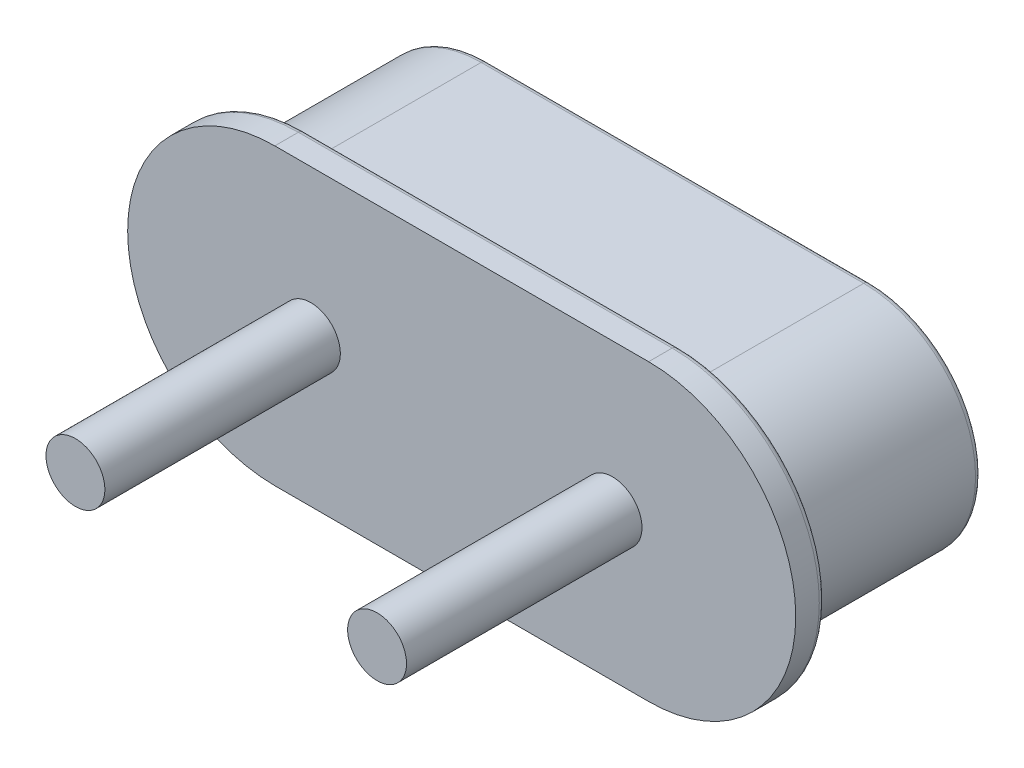
from build123d import *

# Parameters (mm, degrees)
BOSS_EXTRUDE1_DEPTH = 0.5
BOSS_EXTRUDE2_DEPTH = 3.18
FILLET5_R           = 0.1
FILLET6_R           = 0.1
SKETCH7_R           = 0.5
BOSS_EXTRUDE3_DEPTH = 4
BOSS_EXTRUDE4_DEPTH = 0.01


with BuildPart() as part:
    # Sketch1 → Boss-Extrude1 (new body)
    with BuildSketch(Plane.XY):
        with BuildLine():
            Line((-3.175, 2.5), (3.175, 2.5))
            ThreePointArc((3.175, 2.5), (5.675, 0), (3.175, -2.5))
            Line((3.175, -2.5), (-3.175, -2.5))
            ThreePointArc((-3.175, -2.5), (-5.675, 0), (-3.175, 2.5))
        make_face()
    extrude(amount=-BOSS_EXTRUDE1_DEPTH)

    # Sketch3 → Boss-Extrude2 (add)
    with BuildSketch(Plane(origin=(0, 0, -0.5), x_dir=(-1, 0, 0), z_dir=(0, 0, -1))):
        with BuildLine():
            Line((-3.25, 1.9), (3.25, 1.9))
            ThreePointArc((3.25, 1.9), (5.15, 0), (3.25, -1.9))
            Line((3.25, -1.9), (-3.25, -1.9))
            ThreePointArc((-3.25, -1.9), (-5.15, 0), (-3.25, 1.9))
        make_face()
    extrude(amount=BOSS_EXTRUDE2_DEPTH)

    # Fillet5
    fillet5_edges = [part.edges().sort_by_distance(p)[0] for p in [
        (5.15, 0, -3.68),
        (0, -1.9, -3.68),
        (-5.15, 0, -3.68),
        (0, 1.9, -3.68),
    ]]
    fillet(fillet5_edges, radius=FILLET5_R)

    # Fillet6
    fillet6_edges = [part.edges().sort_by_distance(p)[0] for p in [
        (5.675, 0, -0.5),
        (0, 2.5, -0.5),
        (-5.675, 0, -0.5),
        (0, -2.5, -0.5),
    ]]
    fillet(fillet6_edges, radius=FILLET6_R)

    # Sketch7 → Boss-Extrude3 (add)
    with BuildSketch(Plane.XY):
        with Locations((2.5623, 0)):
            Circle(SKETCH7_R)
        with Locations((-2.5623, 0)):
            Circle(SKETCH7_R)
    extrude(amount=BOSS_EXTRUDE3_DEPTH)

    # Sketch8 → Boss-Extrude4 (add)
    with BuildSketch(Plane(origin=(0, 0, -3.68), x_dir=(-1, 0, 0), z_dir=(0, 0, -1))):
        Polygon((-2.690553742, 0.764659829), (-2.413209992, 0.764659829), (-2.413209992, -0.735340171), (-2.547825377, -0.735340171), (-2.547825377, 0.610813675), (-2.778594608, 0.610813675), align=None)
        with BuildLine():
            Line((-1.163209992, 0.803121367), (-1.059544127, 0.721691079))
            Line((-1.059544127, 0.721691079), (-1.455878261, 0.115621367))
            add(Edge.make_bspline(
                [(-1.455878261, 0.115621367), (-1.429491, 0.119827307), (-1.378019663, 0.12803147), (-1.325919992, 0.129384875), (-1.300529704, 0.130044444)],
                knots=[0, 0, 0, 0, 8.0061e-05, 0.000156168, 0.000156168, 0.000156168, 0.000156168], degree=3))
            add(Edge.make_bspline(
                [(-1.300529704, 0.130044444), (-1.285284348, 0.129634682), (-1.255274319, 0.128828077), (-1.211214261, 0.122620713), (-1.168876146, 0.112838522), (-1.128435455, 0.098578984), (-1.089747034, 0.080363689), (-1.052588864, 0.058532745), (-1.017659432, 0.031958882), (-0.984508926, 0.0022739), (-0.954411599, -0.030604807), (-0.927764718, -0.065491094), (-0.905381807, -0.102348615), (-0.887221555, -0.1411587), (-0.873119464, -0.181861526), (-0.862839045, -0.224405014), (-0.856762076, -0.268818502), (-0.855936866, -0.299023434), (-0.855517685, -0.314366614)],
                knots=[0, 0, 0, 0, 4.5721e-05, 9.0001e-05, 0.000133222, 0.000175891, 0.000218368, 0.000261346, 0.000304916, 0.000349809, 0.000394681, 0.000438432, 0.000481307, 0.000523784, 0.000566737, 0.000610319, 0.000654897, 0.000700919, 0.000700919, 0.000700919, 0.000700919], degree=3))
            add(Edge.make_bspline(
                [(-0.855517685, -0.314366614), (-0.856127587, -0.335357915), (-0.85732773, -0.376663829), (-0.869286499, -0.436825275), (-0.887869204, -0.49413921), (-0.914431002, -0.547690569), (-0.947423452, -0.597405956), (-0.987656706, -0.64145687), (-1.033703915, -0.680744029), (-1.085769686, -0.713596866), (-1.141802385, -0.740426745), (-1.200667527, -0.759697563), (-1.261793446, -0.771561907), (-1.303281136, -0.773049308), (-1.324267685, -0.77380171)],
                knots=[0, 0, 0, 0, 6.2904e-05, 0.00012378, 0.000183263, 0.000243197, 0.000302535, 0.000361677, 0.000421581, 0.000483597, 0.000545827, 0.000607495, 0.000668962, 0.000731884, 0.000731884, 0.000731884, 0.000731884], degree=3))
            add(Edge.make_bspline(
                [(-1.324267685, -0.77380171), (-1.344451985, -0.773146764), (-1.38443355, -0.771849432), (-1.443247604, -0.760292602), (-1.499760326, -0.741560986), (-1.553575775, -0.715754867), (-1.603427466, -0.683158631), (-1.648027025, -0.643917655), (-1.687152071, -0.598870741), (-1.719712623, -0.548024878), (-1.745537794, -0.493386325), (-1.764904904, -0.436413258), (-1.77621758, -0.377313266), (-1.77779839, -0.33724992), (-1.778594608, -0.31707094)],
                knots=[0, 0, 0, 0, 6.0504e-05, 0.000119848, 0.000179046, 0.000238718, 0.000298389, 0.000357156, 0.000416376, 0.000476803, 0.000537689, 0.000597267, 0.000656906, 0.000717429, 0.000717429, 0.000717429, 0.000717429], degree=3))
            add(Edge.make_bspline(
                [(-1.778594608, -0.31707094), (-1.778088274, -0.301623262), (-1.777054438, -0.270082054), (-1.769835842, -0.222311756), (-1.758236644, -0.173432721), (-1.745246538, -0.131966638), (-1.731521277, -0.097997415), (-1.72009876, -0.070610204), (-1.705881333, -0.042426887), (-1.690721313, -0.012481043), (-1.673254083, 0.018455571), (-1.654261662, 0.050900001), (-1.633218954, 0.084336255), (-1.618467456, 0.107026625), (-1.610926338, 0.118626175)],
                knots=[0, 0, 0, 0, 4.6336e-05, 9.461e-05, 0.000144609, 0.00019697, 0.000224757, 0.000254506, 0.000285952, 0.000319415, 0.000355196, 0.000392507, 0.000432193, 0.0004737, 0.0004737, 0.0004737, 0.0004737], degree=3))
            Line((-1.610926338, 0.118626175), (-1.163209992, 0.803121367))
        make_face()
        with BuildLine():
            add(Edge.make_bspline(
                [(-1.328774896, -0.02380171), (-1.340201572, -0.024135157), (-1.362521191, -0.024786476), (-1.395267226, -0.028568727), (-1.426258619, -0.035691184), (-1.455905962, -0.044762469), (-1.483654978, -0.057235209), (-1.509707338, -0.07238598), (-1.534163788, -0.090223628), (-1.556768168, -0.110495447), (-1.577262309, -0.132690318), (-1.594911365, -0.15646297), (-1.610135251, -0.181240486), (-1.622513173, -0.20722989), (-1.632151777, -0.234421247), (-1.639123885, -0.262689497), (-1.643004064, -0.292224199), (-1.643649592, -0.312252415), (-1.643979223, -0.322479594)],
                knots=[0, 0, 0, 0, 3.4288e-05, 6.6974e-05, 9.8686e-05, 0.000129571, 0.000159836, 0.000189728, 0.000219839, 0.000250482, 0.00028068, 0.000310307, 0.000339166, 0.000367794, 0.000396495, 0.000425574, 0.000454981, 0.000485667, 0.000485667, 0.000485667, 0.000485667], degree=3))
            add(Edge.make_bspline(
                [(-1.643979223, -0.322479594), (-1.643710782, -0.3326153), (-1.64318441, -0.35248991), (-1.638404845, -0.38177813), (-1.631104095, -0.40996309), (-1.620243925, -0.43689949), (-1.607289545, -0.462997912), (-1.590187263, -0.487313034), (-1.571237212, -0.511321636), (-1.548585526, -0.533179409), (-1.524275513, -0.553517962), (-1.498303569, -0.571295214), (-1.471235015, -0.586503574), (-1.442704406, -0.598422616), (-1.413116527, -0.608204453), (-1.382224861, -0.615087944), (-1.350007923, -0.618979598), (-1.328184235, -0.619625967), (-1.317056146, -0.619955556)],
                knots=[0, 0, 0, 0, 3.0386e-05, 5.9582e-05, 8.8809e-05, 0.000117545, 0.000146572, 0.000175992, 0.000206542, 0.000238201, 0.000270211, 0.000301549, 0.000332485, 0.000363181, 0.000394158, 0.00042587, 0.00045796, 0.000491347, 0.000491347, 0.000491347, 0.000491347], degree=3))
            add(Edge.make_bspline(
                [(-1.317056146, -0.619955556), (-1.305928075, -0.619625941), (-1.284104423, -0.618979522), (-1.251887226, -0.615088235), (-1.220996518, -0.608203386), (-1.191405157, -0.598426484), (-1.162887401, -0.586489223), (-1.13584252, -0.571389829), (-1.110116195, -0.553408636), (-1.085790223, -0.533214166), (-1.063232821, -0.51119723), (-1.043828273, -0.487527349), (-1.027249745, -0.462801394), (-1.01377795, -0.437002298), (-1.003037397, -0.409946803), (-0.995699625, -0.381782493), (-0.99092993, -0.352488768), (-0.990402201, -0.332614914), (-0.990133069, -0.322479594)],
                knots=[0, 0, 0, 0, 3.3387e-05, 6.5477e-05, 9.7189e-05, 0.000128166, 0.000158862, 0.000189798, 0.000220889, 0.000252898, 0.000284557, 0.000315298, 0.000344549, 0.000373715, 0.000402451, 0.000431678, 0.000460874, 0.00049126, 0.00049126, 0.00049126, 0.00049126], degree=3))
            add(Edge.make_bspline(
                [(-0.990133069, -0.322479594), (-0.990368909, -0.312239073), (-0.990831786, -0.292140259), (-0.996067192, -0.262702708), (-1.00332821, -0.23427762), (-1.014292366, -0.207043641), (-1.028536599, -0.181108244), (-1.045886631, -0.156340415), (-1.065957732, -0.132550266), (-1.089142392, -0.11045192), (-1.114381064, -0.090246029), (-1.141216315, -0.072409076), (-1.169291161, -0.057355515), (-1.198577136, -0.044795328), (-1.2294098, -0.035731268), (-1.261291374, -0.028594164), (-1.294629621, -0.024796156), (-1.317248167, -0.024137414), (-1.328774896, -0.02380171)],
                knots=[0, 0, 0, 0, 3.0686e-05, 6.0226e-05, 8.9453e-05, 0.00011858, 0.000148029, 0.000178036, 0.000209162, 0.000241251, 0.000273959, 0.000306045, 0.000337772, 0.000369416, 0.000401449, 0.000434041, 0.000467324, 0.000501912, 0.000501912, 0.000501912, 0.000501912], degree=3))
        make_face(mode=Mode.SUBTRACT)
        with BuildLine():
            add(Edge.make_bspline(
                [(-0.461286915, -0.50457094), (-0.452933967, -0.505067298), (-0.436558989, -0.506040348), (-0.412885077, -0.512716065), (-0.391458794, -0.524569777), (-0.372373546, -0.54036811), (-0.356642199, -0.559523395), (-0.344366048, -0.580778784), (-0.337748483, -0.604650895), (-0.336782521, -0.621120756), (-0.336286915, -0.62957094)],
                knots=[0, 0, 0, 0, 2.5055e-05, 4.9118e-05, 7.3051e-05, 9.802e-05, 0.000122989, 0.000147067, 0.00017113, 0.000196484, 0.000196484, 0.000196484, 0.000196484], degree=3))
            add(Edge.make_bspline(
                [(-0.336286915, -0.62957094), (-0.336799316, -0.637818082), (-0.337809762, -0.654081323), (-0.344350879, -0.677773379), (-0.356735758, -0.699042052), (-0.372265041, -0.718457254), (-0.391463512, -0.734289056), (-0.412935732, -0.746041918), (-0.436503414, -0.753195624), (-0.452924696, -0.754106894), (-0.461286915, -0.75457094)],
                knots=[0, 0, 0, 0, 2.4756e-05, 4.8819e-05, 7.2897e-05, 9.8098e-05, 0.000123067, 0.000147, 0.000171147, 0.000196203, 0.000196203, 0.000196203, 0.000196203], degree=3))
            add(Edge.make_bspline(
                [(-0.461286915, -0.75457094), (-0.469655161, -0.754123685), (-0.485992167, -0.753250524), (-0.509471879, -0.745895035), (-0.531074866, -0.734399267), (-0.550269599, -0.718427734), (-0.565928944, -0.699141958), (-0.577768394, -0.677626903), (-0.584878458, -0.654149144), (-0.585813546, -0.63783144), (-0.586286915, -0.62957094)],
                knots=[0, 0, 0, 0, 2.5055e-05, 4.8915e-05, 7.3112e-05, 9.8081e-05, 0.000123282, 0.000147215, 0.000171362, 0.000196119, 0.000196119, 0.000196119, 0.000196119], degree=3))
            add(Edge.make_bspline(
                [(-0.586286915, -0.62957094), (-0.58583173, -0.621106921), (-0.584943036, -0.604581961), (-0.577753468, -0.5809252), (-0.566020805, -0.559424441), (-0.55016135, -0.540397335), (-0.531079509, -0.524459919), (-0.509523993, -0.512860722), (-0.485935618, -0.50598626), (-0.469645645, -0.505050896), (-0.461286915, -0.50457094)],
                knots=[0, 0, 0, 0, 2.5355e-05, 4.9502e-05, 7.3435e-05, 9.8404e-05, 0.000123372, 0.00014757, 0.000171344, 0.0001964, 0.0001964, 0.0001964, 0.0001964], degree=3))
        make_face()
        with BuildLine():
            add(Edge.make_bspline(
                [(-0.143979223, 0.014058867), (-0.143838644, 0.038100605), (-0.143565567, 0.084802027), (-0.140527672, 0.152852588), (-0.135481097, 0.216692711), (-0.12856508, 0.276325454), (-0.120148803, 0.33176621), (-0.108913594, 0.38286682), (-0.096136679, 0.429863795), (-0.081328488, 0.472910387), (-0.064619435, 0.512586545), (-0.046433323, 0.549625917), (-0.026048411, 0.58397246), (-0.004629734, 0.61617437), (0.018689725, 0.645704525), (0.043246349, 0.672979952), (0.069998582, 0.697370273), (0.098037014, 0.719590117), (0.127615499, 0.739068462), (0.157890927, 0.75622535), (0.189071687, 0.770882436), (0.221242908, 0.782406909), (0.254115433, 0.791925843), (0.287804176, 0.798435392), (0.32236476, 0.80253121), (0.345692518, 0.802922782), (0.357523181, 0.803121367)],
                knots=[0, 0, 0, 0, 7.2121e-05, 0.000140096, 0.000204302, 0.000264197, 0.000320168, 0.000372446, 0.000421069, 0.000466206, 0.000508898, 0.000550152, 0.000589885, 0.000628638, 0.000666087, 0.000702672, 0.00073861, 0.000774558, 0.000809893, 0.000844741, 0.000878887, 0.000913107, 0.000947158, 0.000981455, 0.001015932, 0.001051409, 0.001051409, 0.001051409, 0.001051409], degree=3))
            add(Edge.make_bspline(
                [(0.357523181, 0.803121367), (0.369452672, 0.802912304), (0.393176675, 0.802496542), (0.428251122, 0.798500566), (0.462515271, 0.791870085), (0.495823045, 0.782475382), (0.528448039, 0.770820092), (0.560135071, 0.756211327), (0.591080963, 0.739206098), (0.620793944, 0.719224437), (0.649600207, 0.696946318), (0.676792191, 0.671762317), (0.702372371, 0.643926723), (0.726661788, 0.613737353), (0.748971329, 0.580615174), (0.770217086, 0.54513627), (0.789233673, 0.506680185), (0.807548534, 0.465888556), (0.823357242, 0.421632702), (0.837614204, 0.37416209), (0.849133762, 0.32291601), (0.858729165, 0.268163334), (0.866162692, 0.209702984), (0.871576681, 0.147660277), (0.874436575, 0.081994395), (0.874975161, 0.037098174), (0.875251546, 0.014058867)],
                knots=[0, 0, 0, 0, 3.5777e-05, 7.115e-05, 0.000105742, 0.000140372, 0.000174875, 0.000209565, 0.000244938, 0.00028069, 0.000316874, 0.000354086, 0.000391723, 0.000430204, 0.000470208, 0.000511434, 0.000554167, 0.000598833, 0.000645504, 0.000695036, 0.000747445, 0.000802971, 0.000861746, 0.000924181, 0.000989754, 0.001058875, 0.001058875, 0.001058875, 0.001058875], degree=3))
            add(Edge.make_bspline(
                [(0.875251546, 0.014058867), (0.874972296, -0.00887995), (0.874428187, -0.053575301), (0.871608742, -0.118945719), (0.866055043, -0.180659166), (0.859107905, -0.23886365), (0.849486063, -0.293316916), (0.837655278, -0.344207393), (0.824519425, -0.391754853), (0.808304514, -0.435569772), (0.790557066, -0.476263368), (0.771247696, -0.514263574), (0.750560628, -0.549906271), (0.728022595, -0.582906162), (0.703999703, -0.613497015), (0.677977794, -0.641138854), (0.6506904, -0.666497713), (0.621799365, -0.689062696), (0.591622986, -0.708813327), (0.560783381, -0.726476406), (0.52873336, -0.740718989), (0.496199237, -0.752948292), (0.462715652, -0.762291343), (0.428324341, -0.768751567), (0.39320024, -0.773282359), (0.369456712, -0.773627993), (0.357523181, -0.77380171)],
                knots=[0, 0, 0, 0, 6.8821e-05, 0.000134094, 0.000196229, 0.000254668, 0.000309899, 0.000362015, 0.000411379, 0.000457768, 0.000502037, 0.000544502, 0.000585576, 0.00062558, 0.000664296, 0.000702137, 0.00073935, 0.000775955, 0.000811958, 0.000847477, 0.000882441, 0.000917047, 0.000951677, 0.000986564, 0.001021971, 0.001057748, 0.001057748, 0.001057748, 0.001057748], degree=3))
            add(Edge.make_bspline(
                [(0.357523181, -0.77380171), (0.345692846, -0.773601843), (0.322365736, -0.773207745), (0.28780041, -0.769130432), (0.254250792, -0.762575216), (0.221551326, -0.753396671), (0.189534248, -0.742161742), (0.158635839, -0.727524449), (0.128512546, -0.71066699), (0.099244737, -0.691468953), (0.071382382, -0.669473946), (0.044768694, -0.645146393), (0.020072257, -0.617879217), (-0.002913784, -0.588102964), (-0.024759822, -0.556091575), (-0.044855267, -0.521407986), (-0.063442776, -0.484189725), (-0.080432844, -0.444196334), (-0.095496557, -0.400844222), (-0.108802717, -0.353637432), (-0.119308785, -0.302159302), (-0.12830148, -0.246823287), (-0.135554787, -0.187391603), (-0.140506641, -0.123831984), (-0.143567204, -0.056184037), (-0.143839377, -0.009782705), (-0.143979223, 0.014058867)],
                knots=[0, 0, 0, 0, 3.5477e-05, 6.9954e-05, 0.000104251, 0.000137932, 0.000171767, 0.000205913, 0.000240351, 0.000275271, 0.000310796, 0.000346735, 0.000383319, 0.000421005, 0.000459509, 0.000499501, 0.000541159, 0.000584244, 0.000629764, 0.000678757, 0.000731265, 0.000787284, 0.000846916, 0.000910823, 0.000978497, 0.001050018, 0.001050018, 0.001050018, 0.001050018], degree=3))
        make_face()
        with BuildLine():
            add(Edge.make_bspline(
                [(-0.009363838, 0.014659829), (-0.009312647, -0.005375328), (-0.009213294, -0.044259633), (-0.006617779, -0.100763888), (-0.003081966, -0.153465457), (0.00147859, -0.202431258), (0.008251282, -0.247495549), (0.015839906, -0.288968271), (0.025074801, -0.326629944), (0.036001238, -0.360739006), (0.048446565, -0.391874321), (0.062034792, -0.42084627), (0.076632245, -0.4479971), (0.092969024, -0.473082932), (0.110761194, -0.496185574), (0.129606876, -0.51771393), (0.150209412, -0.536912637), (0.178711016, -0.559938432), (0.216338077, -0.583732346), (0.263746843, -0.604452099), (0.312461894, -0.617473152), (0.345526715, -0.619129047), (0.362030392, -0.619955556)],
                knots=[0, 0, 0, 0, 6.0099e-05, 0.000116641, 0.000169648, 0.000218563, 0.000264117, 0.000306313, 0.000345011, 0.000380361, 0.000413672, 0.00044553, 0.000476322, 0.000506075, 0.000535223, 0.000563745, 0.000591804, 0.000619586, 0.000673605, 0.00072474, 0.00077437, 0.000823828, 0.000823828, 0.000823828, 0.000823828], degree=3))
            add(Edge.make_bspline(
                [(0.362030392, -0.619955556), (0.378640823, -0.619270793), (0.41182739, -0.61790268), (0.460313302, -0.604703221), (0.507383418, -0.584787704), (0.544271393, -0.561238773), (0.57233534, -0.538812346), (0.592442621, -0.519691783), (0.610897785, -0.498282125), (0.628401531, -0.475182427), (0.644455421, -0.449951363), (0.659053908, -0.422710259), (0.672375343, -0.393383468), (0.679964934, -0.372910723), (0.683845296, -0.362443537)],
                knots=[0, 0, 0, 0, 4.9733e-05, 9.9363e-05, 0.000149708, 0.000202645, 0.000230003, 0.000257419, 0.000285743, 0.000314709, 0.0003443, 0.000375356, 0.000407361, 0.000440843, 0.000440843, 0.000440843, 0.000440843], degree=3))
            add(Edge.make_bspline(
                [(0.683845296, -0.362443537), (0.688367482, -0.349059363), (0.69754946, -0.321883749), (0.709383077, -0.279727898), (0.718702534, -0.235498142), (0.727086834, -0.189458807), (0.732809572, -0.141270363), (0.737415778, -0.091081913), (0.740128929, -0.038855615), (0.740465251, -0.003372047), (0.740636162, 0.014659829)],
                knots=[0, 0, 0, 0, 4.238e-05, 8.6049e-05, 0.000131254, 0.000177938, 0.000226389, 0.000276771, 0.000329125, 0.000383219, 0.000383219, 0.000383219, 0.000383219], degree=3))
            add(Edge.make_bspline(
                [(0.740636162, 0.014659829), (0.740400366, 0.032688788), (0.7399391, 0.067957288), (0.738175962, 0.119607936), (0.733623002, 0.168665548), (0.728566237, 0.215341465), (0.721110285, 0.259377309), (0.713071225, 0.301141726), (0.702270705, 0.340117308), (0.690733659, 0.376914271), (0.677529204, 0.411114552), (0.662993889, 0.442877603), (0.647470278, 0.472356771), (0.630609318, 0.499471174), (0.612611168, 0.524342264), (0.59300079, 0.546471376), (0.572556058, 0.566544363), (0.543920122, 0.589456892), (0.50643114, 0.612819047), (0.459783006, 0.634318659), (0.411238444, 0.64666507), (0.378421249, 0.648405793), (0.362030392, 0.649275213)],
                knots=[0, 0, 0, 0, 5.4094e-05, 0.00010582, 0.000154978, 0.000201866, 0.000246621, 0.000288933, 0.000329386, 0.000367872, 0.00040459, 0.000439281, 0.000472617, 0.000504467, 0.000534998, 0.000564594, 0.000593068, 0.000620849, 0.000674455, 0.000725161, 0.000774426, 0.000823585, 0.000823585, 0.000823585, 0.000823585], degree=3))
            add(Edge.make_bspline(
                [(0.362030392, 0.649275213), (0.345440139, 0.648404593), (0.312229408, 0.646661767), (0.263180284, 0.634364659), (0.216164133, 0.61293053), (0.178774287, 0.589379514), (0.150118379, 0.566948809), (0.129940082, 0.547497471), (0.111020293, 0.526220505), (0.093591279, 0.502905399), (0.077267301, 0.477848813), (0.062275438, 0.450853628), (0.048768011, 0.421783043), (0.03630321, 0.390661714), (0.025343444, 0.356555595), (0.016303174, 0.318940312), (0.007951579, 0.277599501), (0.002039321, 0.23229114), (-0.003216574, 0.183313075), (-0.006594295, 0.130479938), (-0.009221976, 0.073880918), (-0.009315604, 0.034795564), (-0.009363838, 0.014659829)],
                knots=[0, 0, 0, 0, 4.9757e-05, 9.9606e-05, 0.000150586, 0.000204192, 0.000231785, 0.000259626, 0.000288148, 0.000317115, 0.000346868, 0.000377805, 0.000409663, 0.000442974, 0.000478324, 0.000517022, 0.00055898, 0.000604789, 0.000654033, 0.00070674, 0.000763582, 0.000823982, 0.000823982, 0.000823982, 0.000823982], degree=3))
        make_face(mode=Mode.SUBTRACT)
        with BuildLine():
            add(Edge.make_bspline(
                [(1.009866931, 0.014058867), (1.01000751, 0.038100605), (1.010280587, 0.084802027), (1.013318482, 0.152852588), (1.018365057, 0.216692711), (1.025281074, 0.276325454), (1.033697351, 0.33176621), (1.04493256, 0.38286682), (1.057709475, 0.429863795), (1.072517666, 0.472910387), (1.089226719, 0.512586545), (1.107412831, 0.549625917), (1.127797742, 0.58397246), (1.149216419, 0.61617437), (1.172535879, 0.645704525), (1.197092503, 0.672979952), (1.223844736, 0.697370273), (1.251883168, 0.719590117), (1.281461653, 0.739068462), (1.311737081, 0.75622535), (1.342917841, 0.770882436), (1.375089062, 0.782406909), (1.407961587, 0.791925843), (1.44165033, 0.798435392), (1.476210914, 0.80253121), (1.499538672, 0.802922782), (1.511369335, 0.803121367)],
                knots=[0, 0, 0, 0, 7.2121e-05, 0.000140096, 0.000204302, 0.000264197, 0.000320168, 0.000372446, 0.000421069, 0.000466206, 0.000508898, 0.000550152, 0.000589885, 0.000628638, 0.000666087, 0.000702672, 0.00073861, 0.000774558, 0.000809893, 0.000844741, 0.000878887, 0.000913107, 0.000947158, 0.000981455, 0.001015932, 0.001051409, 0.001051409, 0.001051409, 0.001051409], degree=3))
            add(Edge.make_bspline(
                [(1.511369335, 0.803121367), (1.523298825, 0.802912304), (1.547022829, 0.802496542), (1.582097276, 0.798500566), (1.616361425, 0.791870085), (1.649669199, 0.782475382), (1.682294193, 0.770820092), (1.713981225, 0.756211327), (1.744927117, 0.739206098), (1.774640097, 0.719224437), (1.803446361, 0.696946318), (1.830638345, 0.671762317), (1.856218525, 0.643926723), (1.880507941, 0.613737353), (1.902817483, 0.580615174), (1.92406324, 0.54513627), (1.943079827, 0.506680185), (1.961394687, 0.465888556), (1.977203396, 0.421632702), (1.991460358, 0.37416209), (2.002979916, 0.32291601), (2.012575319, 0.268163334), (2.020008846, 0.209702984), (2.025422835, 0.147660277), (2.028282729, 0.081994395), (2.028821315, 0.037098174), (2.0290977, 0.014058867)],
                knots=[0, 0, 0, 0, 3.5777e-05, 7.115e-05, 0.000105742, 0.000140372, 0.000174875, 0.000209565, 0.000244938, 0.00028069, 0.000316874, 0.000354086, 0.000391723, 0.000430204, 0.000470208, 0.000511434, 0.000554167, 0.000598833, 0.000645504, 0.000695036, 0.000747445, 0.000802971, 0.000861746, 0.000924181, 0.000989754, 0.001058875, 0.001058875, 0.001058875, 0.001058875], degree=3))
            add(Edge.make_bspline(
                [(2.0290977, 0.014058867), (2.02881845, -0.00887995), (2.028274341, -0.053575301), (2.025454896, -0.118945719), (2.019901196, -0.180659166), (2.012954059, -0.23886365), (2.003332217, -0.293316916), (1.991501432, -0.344207393), (1.978365579, -0.391754853), (1.962150667, -0.435569772), (1.94440322, -0.476263368), (1.92509385, -0.514263574), (1.904406782, -0.549906271), (1.881868748, -0.582906162), (1.857845857, -0.613497015), (1.831823948, -0.641138854), (1.804536554, -0.666497713), (1.775645519, -0.689062696), (1.74546914, -0.708813327), (1.714629535, -0.726476406), (1.682579514, -0.740718989), (1.650045391, -0.752948292), (1.616561806, -0.762291343), (1.582170495, -0.768751567), (1.547046394, -0.773282359), (1.523302866, -0.773627993), (1.511369335, -0.77380171)],
                knots=[0, 0, 0, 0, 6.8821e-05, 0.000134094, 0.000196229, 0.000254668, 0.000309899, 0.000362015, 0.000411379, 0.000457768, 0.000502037, 0.000544502, 0.000585576, 0.00062558, 0.000664296, 0.000702137, 0.00073935, 0.000775955, 0.000811958, 0.000847477, 0.000882441, 0.000917047, 0.000951677, 0.000986564, 0.001021971, 0.001057748, 0.001057748, 0.001057748, 0.001057748], degree=3))
            add(Edge.make_bspline(
                [(1.511369335, -0.77380171), (1.499539, -0.773601843), (1.476211889, -0.773207745), (1.441646564, -0.769130432), (1.408096946, -0.762575216), (1.37539748, -0.753396671), (1.343380402, -0.742161742), (1.312481993, -0.727524449), (1.2823587, -0.71066699), (1.25309089, -0.691468953), (1.225228536, -0.669473946), (1.198614848, -0.645146393), (1.173918411, -0.617879217), (1.15093237, -0.588102964), (1.129086332, -0.556091575), (1.108990887, -0.521407986), (1.090403378, -0.484189725), (1.07341331, -0.444196334), (1.058349597, -0.400844222), (1.045043437, -0.353637432), (1.034537369, -0.302159302), (1.025544674, -0.246823287), (1.018291367, -0.187391603), (1.013339513, -0.123831984), (1.01027895, -0.056184037), (1.010006777, -0.009782705), (1.009866931, 0.014058867)],
                knots=[0, 0, 0, 0, 3.5477e-05, 6.9954e-05, 0.000104251, 0.000137932, 0.000171767, 0.000205913, 0.000240351, 0.000275271, 0.000310796, 0.000346735, 0.000383319, 0.000421005, 0.000459509, 0.000499501, 0.000541159, 0.000584244, 0.000629764, 0.000678757, 0.000731265, 0.000787284, 0.000846916, 0.000910823, 0.000978497, 0.001050018, 0.001050018, 0.001050018, 0.001050018], degree=3))
        make_face()
        with BuildLine():
            add(Edge.make_bspline(
                [(1.144482315, 0.014659829), (1.144533507, -0.005375328), (1.14463286, -0.044259633), (1.147228374, -0.100763888), (1.150764188, -0.153465457), (1.155324744, -0.202431258), (1.162097436, -0.247495549), (1.16968606, -0.288968271), (1.178920955, -0.326629944), (1.189847391, -0.360739006), (1.202292719, -0.391874321), (1.215880946, -0.42084627), (1.230478399, -0.4479971), (1.246815177, -0.473082932), (1.264607347, -0.496185574), (1.28345303, -0.51771393), (1.304055566, -0.536912637), (1.33255717, -0.559938432), (1.37018423, -0.583732346), (1.417592997, -0.604452099), (1.466308047, -0.617473152), (1.499372869, -0.619129047), (1.515876546, -0.619955556)],
                knots=[0, 0, 0, 0, 6.0099e-05, 0.000116641, 0.000169648, 0.000218563, 0.000264117, 0.000306313, 0.000345011, 0.000380361, 0.000413672, 0.00044553, 0.000476322, 0.000506075, 0.000535223, 0.000563745, 0.000591804, 0.000619586, 0.000673605, 0.00072474, 0.00077437, 0.000823828, 0.000823828, 0.000823828, 0.000823828], degree=3))
            add(Edge.make_bspline(
                [(1.515876546, -0.619955556), (1.532486977, -0.619270793), (1.565673544, -0.61790268), (1.614159456, -0.604703221), (1.661229572, -0.584787704), (1.698117546, -0.561238773), (1.726181494, -0.538812346), (1.746288775, -0.519691783), (1.764743939, -0.498282125), (1.782247685, -0.475182427), (1.798301575, -0.449951363), (1.812900062, -0.422710259), (1.826221497, -0.393383468), (1.833811088, -0.372910723), (1.83769145, -0.362443537)],
                knots=[0, 0, 0, 0, 4.9733e-05, 9.9363e-05, 0.000149708, 0.000202645, 0.000230003, 0.000257419, 0.000285743, 0.000314709, 0.0003443, 0.000375356, 0.000407361, 0.000440843, 0.000440843, 0.000440843, 0.000440843], degree=3))
            add(Edge.make_bspline(
                [(1.83769145, -0.362443537), (1.842213636, -0.349059363), (1.851395614, -0.321883749), (1.863229231, -0.279727898), (1.872548688, -0.235498142), (1.880932988, -0.189458807), (1.886655726, -0.141270363), (1.891261932, -0.091081913), (1.893975083, -0.038855615), (1.894311405, -0.003372047), (1.894482315, 0.014659829)],
                knots=[0, 0, 0, 0, 4.238e-05, 8.6049e-05, 0.000131254, 0.000177938, 0.000226389, 0.000276771, 0.000329125, 0.000383219, 0.000383219, 0.000383219, 0.000383219], degree=3))
            add(Edge.make_bspline(
                [(1.894482315, 0.014659829), (1.89424652, 0.032688788), (1.893785254, 0.067957288), (1.892022116, 0.119607936), (1.887469156, 0.168665548), (1.882412391, 0.215341465), (1.874956439, 0.259377309), (1.866917379, 0.301141726), (1.856116859, 0.340117308), (1.844579813, 0.376914271), (1.831375357, 0.411114552), (1.816840043, 0.442877603), (1.801316432, 0.472356771), (1.784455472, 0.499471174), (1.766457322, 0.524342264), (1.746846943, 0.546471376), (1.726402212, 0.566544363), (1.697766276, 0.589456892), (1.660277294, 0.612819047), (1.61362916, 0.634318659), (1.565084598, 0.64666507), (1.532267403, 0.648405793), (1.515876546, 0.649275213)],
                knots=[0, 0, 0, 0, 5.4094e-05, 0.00010582, 0.000154978, 0.000201866, 0.000246621, 0.000288933, 0.000329386, 0.000367872, 0.00040459, 0.000439281, 0.000472617, 0.000504467, 0.000534998, 0.000564594, 0.000593068, 0.000620849, 0.000674455, 0.000725161, 0.000774426, 0.000823585, 0.000823585, 0.000823585, 0.000823585], degree=3))
            add(Edge.make_bspline(
                [(1.515876546, 0.649275213), (1.499286292, 0.648404593), (1.466075561, 0.646661767), (1.417026438, 0.634364659), (1.370010287, 0.61293053), (1.332620441, 0.589379514), (1.303964533, 0.566948809), (1.283786235, 0.547497471), (1.264866447, 0.526220505), (1.247437433, 0.502905399), (1.231113454, 0.477848813), (1.216121592, 0.450853628), (1.202614165, 0.421783043), (1.190149364, 0.390661714), (1.179189597, 0.356555595), (1.170149327, 0.318940312), (1.161797733, 0.277599501), (1.155885475, 0.23229114), (1.15062958, 0.183313075), (1.147251859, 0.130479938), (1.144624177, 0.073880918), (1.14453055, 0.034795564), (1.144482315, 0.014659829)],
                knots=[0, 0, 0, 0, 4.9757e-05, 9.9606e-05, 0.000150586, 0.000204192, 0.000231785, 0.000259626, 0.000288148, 0.000317115, 0.000346868, 0.000377805, 0.000409663, 0.000442974, 0.000478324, 0.000517022, 0.00055898, 0.000604789, 0.000654033, 0.00070674, 0.000763582, 0.000823982, 0.000823982, 0.000823982, 0.000823982], degree=3))
        make_face(mode=Mode.SUBTRACT)
        with BuildLine():
            add(Edge.make_bspline(
                [(2.163713085, 0.014058867), (2.163853664, 0.038100605), (2.164126741, 0.084802027), (2.167164636, 0.152852588), (2.172211211, 0.216692711), (2.179127228, 0.276325454), (2.187543505, 0.33176621), (2.198778714, 0.38286682), (2.211555629, 0.429863795), (2.22636382, 0.472910387), (2.243072873, 0.512586545), (2.261258984, 0.549625917), (2.281643896, 0.58397246), (2.303062573, 0.61617437), (2.326382032, 0.645704525), (2.350938657, 0.672979952), (2.37769089, 0.697370273), (2.405729322, 0.719590117), (2.435307807, 0.739068462), (2.465583235, 0.75622535), (2.496763995, 0.770882436), (2.528935216, 0.782406909), (2.561807741, 0.791925843), (2.595496483, 0.798435392), (2.630057068, 0.80253121), (2.653384826, 0.802922782), (2.665215489, 0.803121367)],
                knots=[0, 0, 0, 0, 7.2121e-05, 0.000140096, 0.000204302, 0.000264197, 0.000320168, 0.000372446, 0.000421069, 0.000466206, 0.000508898, 0.000550152, 0.000589885, 0.000628638, 0.000666087, 0.000702672, 0.00073861, 0.000774558, 0.000809893, 0.000844741, 0.000878887, 0.000913107, 0.000947158, 0.000981455, 0.001015932, 0.001051409, 0.001051409, 0.001051409, 0.001051409], degree=3))
            add(Edge.make_bspline(
                [(2.665215489, 0.803121367), (2.677144979, 0.802912304), (2.700868983, 0.802496542), (2.73594343, 0.798500566), (2.770207579, 0.791870085), (2.803515353, 0.782475382), (2.836140347, 0.770820092), (2.867827379, 0.756211327), (2.898773271, 0.739206098), (2.928486251, 0.719224437), (2.957292515, 0.696946318), (2.984484499, 0.671762317), (3.010064679, 0.643926723), (3.034354095, 0.613737353), (3.056663637, 0.580615174), (3.077909394, 0.54513627), (3.09692598, 0.506680185), (3.115240841, 0.465888556), (3.13104955, 0.421632702), (3.145306512, 0.37416209), (3.15682607, 0.32291601), (3.166421473, 0.268163334), (3.173854999, 0.209702984), (3.179268989, 0.147660277), (3.182128882, 0.081994395), (3.182667469, 0.037098174), (3.182943854, 0.014058867)],
                knots=[0, 0, 0, 0, 3.5777e-05, 7.115e-05, 0.000105742, 0.000140372, 0.000174875, 0.000209565, 0.000244938, 0.00028069, 0.000316874, 0.000354086, 0.000391723, 0.000430204, 0.000470208, 0.000511434, 0.000554167, 0.000598833, 0.000645504, 0.000695036, 0.000747445, 0.000802971, 0.000861746, 0.000924181, 0.000989754, 0.001058875, 0.001058875, 0.001058875, 0.001058875], degree=3))
            add(Edge.make_bspline(
                [(3.182943854, 0.014058867), (3.182664603, -0.00887995), (3.182120495, -0.053575301), (3.179301049, -0.118945719), (3.17374735, -0.180659166), (3.166800212, -0.23886365), (3.157178371, -0.293316916), (3.145347586, -0.344207393), (3.132211733, -0.391754853), (3.115996821, -0.435569772), (3.098249374, -0.476263368), (3.078940004, -0.514263574), (3.058252936, -0.549906271), (3.035714902, -0.582906162), (3.011692011, -0.613497015), (2.985670101, -0.641138854), (2.958382708, -0.666497713), (2.929491672, -0.689062696), (2.899315293, -0.708813327), (2.868475689, -0.726476406), (2.836425668, -0.740718989), (2.803891545, -0.752948292), (2.770407959, -0.762291343), (2.736016649, -0.768751567), (2.700892548, -0.773282359), (2.67714902, -0.773627993), (2.665215489, -0.77380171)],
                knots=[0, 0, 0, 0, 6.8821e-05, 0.000134094, 0.000196229, 0.000254668, 0.000309899, 0.000362015, 0.000411379, 0.000457768, 0.000502037, 0.000544502, 0.000585576, 0.00062558, 0.000664296, 0.000702137, 0.00073935, 0.000775955, 0.000811958, 0.000847477, 0.000882441, 0.000917047, 0.000951677, 0.000986564, 0.001021971, 0.001057748, 0.001057748, 0.001057748, 0.001057748], degree=3))
            add(Edge.make_bspline(
                [(2.665215489, -0.77380171), (2.653385154, -0.773601843), (2.630058043, -0.773207745), (2.595492718, -0.769130432), (2.5619431, -0.762575216), (2.529243634, -0.753396671), (2.497226556, -0.742161742), (2.466328147, -0.727524449), (2.436204854, -0.71066699), (2.406937044, -0.691468953), (2.37907469, -0.669473946), (2.352461002, -0.645146393), (2.327764565, -0.617879217), (2.304778524, -0.588102964), (2.282932486, -0.556091575), (2.26283704, -0.521407986), (2.244249531, -0.484189725), (2.227259464, -0.444196334), (2.212195751, -0.400844222), (2.19888959, -0.353637432), (2.188383523, -0.302159302), (2.179390828, -0.246823287), (2.172137521, -0.187391603), (2.167185667, -0.123831984), (2.164125104, -0.056184037), (2.163852931, -0.009782705), (2.163713085, 0.014058867)],
                knots=[0, 0, 0, 0, 3.5477e-05, 6.9954e-05, 0.000104251, 0.000137932, 0.000171767, 0.000205913, 0.000240351, 0.000275271, 0.000310796, 0.000346735, 0.000383319, 0.000421005, 0.000459509, 0.000499501, 0.000541159, 0.000584244, 0.000629764, 0.000678757, 0.000731265, 0.000787284, 0.000846916, 0.000910823, 0.000978497, 0.001050018, 0.001050018, 0.001050018, 0.001050018], degree=3))
        make_face()
        with BuildLine():
            add(Edge.make_bspline(
                [(2.298328469, 0.014659829), (2.298379661, -0.005375328), (2.298479014, -0.044259633), (2.301074528, -0.100763888), (2.304610342, -0.153465457), (2.309170898, -0.202431258), (2.31594359, -0.247495549), (2.323532213, -0.288968271), (2.332767109, -0.326629944), (2.343693545, -0.360739006), (2.356138873, -0.391874321), (2.3697271, -0.42084627), (2.384324552, -0.4479971), (2.400661331, -0.473082932), (2.418453501, -0.496185574), (2.437299184, -0.51771393), (2.45790172, -0.536912637), (2.486403324, -0.559938432), (2.524030384, -0.583732346), (2.571439151, -0.604452099), (2.620154201, -0.617473152), (2.653219023, -0.619129047), (2.6697227, -0.619955556)],
                knots=[0, 0, 0, 0, 6.0099e-05, 0.000116641, 0.000169648, 0.000218563, 0.000264117, 0.000306313, 0.000345011, 0.000380361, 0.000413672, 0.00044553, 0.000476322, 0.000506075, 0.000535223, 0.000563745, 0.000591804, 0.000619586, 0.000673605, 0.00072474, 0.00077437, 0.000823828, 0.000823828, 0.000823828, 0.000823828], degree=3))
            add(Edge.make_bspline(
                [(2.6697227, -0.619955556), (2.686333131, -0.619270793), (2.719519698, -0.61790268), (2.76800561, -0.604703221), (2.815075726, -0.584787704), (2.8519637, -0.561238773), (2.880027647, -0.538812346), (2.900134929, -0.519691783), (2.918590093, -0.498282125), (2.936093839, -0.475182427), (2.952147728, -0.449951363), (2.966746216, -0.422710259), (2.980067651, -0.393383468), (2.987657242, -0.372910723), (2.991537604, -0.362443537)],
                knots=[0, 0, 0, 0, 4.9733e-05, 9.9363e-05, 0.000149708, 0.000202645, 0.000230003, 0.000257419, 0.000285743, 0.000314709, 0.0003443, 0.000375356, 0.000407361, 0.000440843, 0.000440843, 0.000440843, 0.000440843], degree=3))
            add(Edge.make_bspline(
                [(2.991537604, -0.362443537), (2.99605979, -0.349059363), (3.005241767, -0.321883749), (3.017075385, -0.279727898), (3.026394842, -0.235498142), (3.034779141, -0.189458807), (3.04050188, -0.141270363), (3.045108085, -0.091081913), (3.047821237, -0.038855615), (3.048157559, -0.003372047), (3.048328469, 0.014659829)],
                knots=[0, 0, 0, 0, 4.238e-05, 8.6049e-05, 0.000131254, 0.000177938, 0.000226389, 0.000276771, 0.000329125, 0.000383219, 0.000383219, 0.000383219, 0.000383219], degree=3))
            add(Edge.make_bspline(
                [(3.048328469, 0.014659829), (3.048092674, 0.032688788), (3.047631408, 0.067957288), (3.04586827, 0.119607936), (3.04131531, 0.168665548), (3.036258544, 0.215341465), (3.028802593, 0.259377309), (3.020763532, 0.301141726), (3.009963013, 0.340117308), (2.998425966, 0.376914271), (2.985221511, 0.411114552), (2.970686197, 0.442877603), (2.955162586, 0.472356771), (2.938301625, 0.499471174), (2.920303476, 0.524342264), (2.900693097, 0.546471376), (2.880248366, 0.566544363), (2.851612429, 0.589456892), (2.814123448, 0.612819047), (2.767475313, 0.634318659), (2.718930752, 0.64666507), (2.686113557, 0.648405793), (2.6697227, 0.649275213)],
                knots=[0, 0, 0, 0, 5.4094e-05, 0.00010582, 0.000154978, 0.000201866, 0.000246621, 0.000288933, 0.000329386, 0.000367872, 0.00040459, 0.000439281, 0.000472617, 0.000504467, 0.000534998, 0.000564594, 0.000593068, 0.000620849, 0.000674455, 0.000725161, 0.000774426, 0.000823585, 0.000823585, 0.000823585, 0.000823585], degree=3))
            add(Edge.make_bspline(
                [(2.6697227, 0.649275213), (2.653132446, 0.648404593), (2.619921715, 0.646661767), (2.570872592, 0.634364659), (2.523856441, 0.61293053), (2.486466595, 0.589379514), (2.457810686, 0.566948809), (2.437632389, 0.547497471), (2.418712601, 0.526220505), (2.401283587, 0.502905399), (2.384959608, 0.477848813), (2.369967746, 0.450853628), (2.356460319, 0.421783043), (2.343995518, 0.390661714), (2.333035751, 0.356555595), (2.323995481, 0.318940312), (2.315643887, 0.277599501), (2.309731629, 0.23229114), (2.304475734, 0.183313075), (2.301098013, 0.130479938), (2.298470331, 0.073880918), (2.298376704, 0.034795564), (2.298328469, 0.014659829)],
                knots=[0, 0, 0, 0, 4.9757e-05, 9.9606e-05, 0.000150586, 0.000204192, 0.000231785, 0.000259626, 0.000288148, 0.000317115, 0.000346868, 0.000377805, 0.000409663, 0.000442974, 0.000478324, 0.000517022, 0.00055898, 0.000604789, 0.000654033, 0.00070674, 0.000763582, 0.000823982, 0.000823982, 0.000823982, 0.000823982], degree=3))
        make_face(mode=Mode.SUBTRACT)
    extrude(amount=BOSS_EXTRUDE4_DEPTH)


solid = part.part
